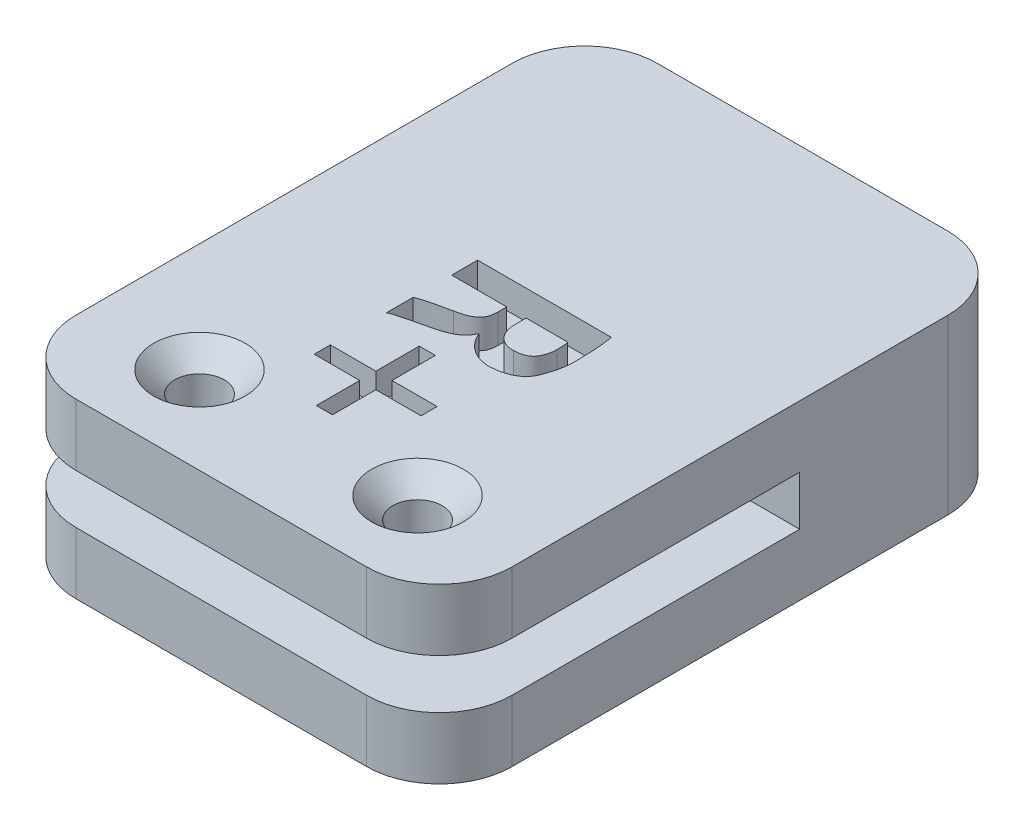
from build123d import *

# Parameters (mm, degrees)
BOSS_EXTRUDE1_DEPTH                                 = 4.25
BOSS_EXTRUDE2_DEPTH                                 = 30
FILLET1_R                                           = 5
CSK_FOR_M3_COUNTERSUNK_FLAT_HEAD_SCREW1_D           = 3.4
CSK_FOR_M3_COUNTERSUNK_FLAT_HEAD_SCREW1_CSINK_D     = 6.3
CSK_FOR_M3_COUNTERSUNK_FLAT_HEAD_SCREW1_CSINK_ANGLE = 90
CUT_EXTRUDE3_DEPTH                                  = 2


with BuildPart() as part:
    # Sketch1 → Boss-Extrude1 (new body)
    with BuildSketch(Plane(origin=(0, 0, 0), x_dir=(1, 0, 0), z_dir=(0, 1, 0))):
        with BuildLine():
            Line((15, 15), (15, 20))
            Line((15, 20), (10, 20))
            Line((10, 20), (-10, 20))
            ThreePointArc((-10, 20), (-13.535533906, 18.535533906), (-15, 15))
            Line((-15, 15), (-15, -15))
            ThreePointArc((-15, -15), (-13.535533906, -18.535533906), (-10, -20))
            Line((-10, -20), (10, -20))
            ThreePointArc((10, -20), (13.535533906, -18.535533906), (15, -15))
            Line((15, -15), (15, 15))
        make_face()
    extrude(amount=BOSS_EXTRUDE1_DEPTH)

    # Sketch8 → Boss-Extrude2 (add)
    with BuildSketch(Plane(origin=(15, 0, 0), x_dir=(0, 0, -1), z_dir=(1, 0, 0))):
        Polygon((4.788040489, 0), (20, 0), (20, -7.65), (5.253900522, -7.65), (-20, -7.65), (-20, -3.4), (4.788040489, -3.4), align=None)
    extrude(amount=-BOSS_EXTRUDE2_DEPTH)

    # Fillet1
    fillet1_edges = [part.edges().sort_by_distance(p)[0] for p in [
        (-15, -5.525, 20),
        (15, -5.525, 20),
        (-15, -3.825, -20),
        (15, -1.7, -20),
    ]]
    fillet(fillet1_edges, radius=FILLET1_R)

    # CSK for M3 Countersunk Flat Head Screw1 (through all)
    with Locations(Plane(origin=(7.5, 4.25, 14), x_dir=(0, 0, 1), z_dir=(0, 1, 0))):
        with Locations((0, 0), (0, -15)):
            CounterSinkHole(CSK_FOR_M3_COUNTERSUNK_FLAT_HEAD_SCREW1_D / 2, CSK_FOR_M3_COUNTERSUNK_FLAT_HEAD_SCREW1_CSINK_D / 2, counter_sink_angle=CSK_FOR_M3_COUNTERSUNK_FLAT_HEAD_SCREW1_CSINK_ANGLE)

    # Sketch16 → Cut-Extrude3 (cut)
    with BuildSketch(Plane(origin=(0, 4.25, 0), x_dir=(1, 0, 0), z_dir=(0, 1, 0))):
        with BuildLine():
            Line((-4.458875061, 2.093953282), (-4.458875061, 0.309949228))
            Line((-4.458875061, 0.309949228), (-0.672122679, 0.309949228))
            Line((-0.672122679, 0.309949228), (-0.672122679, -0.295533742))
            add(Edge.make_bspline(
                [(-0.672122679, -0.295533742), (-0.672504144, -0.346007588), (-0.673250223, -0.444725636), (-0.687535915, -0.588091446), (-0.711269814, -0.723049373), (-0.748906576, -0.848005309), (-0.795186736, -0.964950699), (-0.856795731, -1.071025204), (-0.926036377, -1.170327836), (-1.010647749, -1.259432456), (-1.109289731, -1.34061223), (-1.221698501, -1.418754612), (-1.353111911, -1.488366917), (-1.500999377, -1.552487837), (-1.66430924, -1.614037158), (-1.844048215, -1.67060951), (-2.041510814, -1.718785961), (-2.179182831, -1.747242983), (-2.25068209, -1.762021993)],
                knots=[0, 0, 0, 0, 0.000151354, 0.000296022, 0.000431716, 0.000561725, 0.000686937, 0.000808031, 0.00092887, 0.001049364, 0.001175264, 0.001311639, 0.001459344, 0.001620515, 0.001794996, 0.001982705, 0.00218542, 0.002404451, 0.002404451, 0.002404451, 0.002404451], degree=3))
            add(Edge.make_bspline(
                [(-2.25068209, -1.762021993), (-2.387123246, -1.789200508), (-2.648649934, -1.841295546), (-3.023584407, -1.921428366), (-3.362673147, -2.002832785), (-3.666100231, -2.077858492), (-3.927379781, -2.154644362), (-4.146751884, -2.219240543), (-4.32008565, -2.279378782), (-4.417682148, -2.322811057), (-4.45961412, -2.341471572)],
                knots=[0, 0, 0, 0, 0.000417367, 0.000799998, 0.001150089, 0.001463532, 0.001737527, 0.001966934, 0.002149658, 0.002287303, 0.002287303, 0.002287303, 0.002287303], degree=3))
            Line((-4.45961412, -2.341471572), (-4.458875061, -4.175738487))
            add(Edge.make_bspline(
                [(-4.458875061, -4.175738487), (-4.402589194, -4.151927467), (-4.273325007, -4.097243897), (-4.049026625, -4.021563183), (-3.76980856, -3.944375115), (-3.44421419, -3.85993596), (-3.082911414, -3.77340803), (-2.69996289, -3.679173777), (-2.299298994, -3.5850796), (-2.02650801, -3.520868388), (-1.887209172, -3.488079375)],
                knots=[0, 0, 0, 0, 0.000183303, 0.000420968, 0.000709434, 0.001052273, 0.001430025, 0.001823964, 0.002235386, 0.002664705, 0.002664705, 0.002664705, 0.002664705], degree=3))
            add(Edge.make_bspline(
                [(-1.887209172, -3.488079375), (-1.773168942, -3.460587046), (-1.5527428, -3.40744766), (-1.242137194, -3.301932392), (-0.961961493, -3.180824272), (-0.712628496, -3.043118308), (-0.494327391, -2.883770123), (-0.309294243, -2.700614679), (-0.160659908, -2.489955128), (-0.089741414, -2.335127445), (-0.054041414, -2.257187997)],
                knots=[0, 0, 0, 0, 0.000351778, 0.000679945, 0.00098268, 0.001266475, 0.001532679, 0.001790935, 0.002044255, 0.002301038, 0.002301038, 0.002301038, 0.002301038], degree=3))
            Line((-0.054041414, -2.257187997), (-0.017001018, -2.256815895))
            add(Edge.make_bspline(
                [(-0.017001018, -2.256815895), (0.029911866, -2.365823451), (0.123313913, -2.582853997), (0.323884915, -2.877351795), (0.561124066, -3.147418036), (0.791801521, -3.347016191), (0.996667391, -3.486871195), (1.159796885, -3.579888369), (1.331125187, -3.659692635), (1.511272618, -3.724161338), (1.699423762, -3.777423006), (1.896777905, -3.815590183), (2.10218195, -3.840681678), (2.242029099, -3.845564971), (2.31292232, -3.848040477)],
                knots=[0, 0, 0, 0, 0.000355311, 0.000707414, 0.001063218, 0.001431749, 0.001618768, 0.001806724, 0.001994483, 0.002185005, 0.002380132, 0.002580552, 0.002787459, 0.003000185, 0.003000185, 0.003000185, 0.003000185], degree=3))
            add(Edge.make_bspline(
                [(2.31292232, -3.848040477), (2.385587327, -3.843063086), (2.528387107, -3.833281621), (2.736157027, -3.804081983), (2.934377079, -3.769477794), (3.12157362, -3.72614897), (3.298551, -3.672971002), (3.465300172, -3.611887222), (3.621747563, -3.542152622), (3.767015737, -3.462240208), (3.901655002, -3.374411599), (4.028165561, -3.280431232), (4.139686737, -3.173179002), (4.245201989, -3.061210534), (4.337161514, -2.937791912), (4.421171972, -2.806974416), (4.492481699, -2.666595654), (4.572833747, -2.470528249), (4.655111908, -2.221765184), (4.747022893, -1.928865862), (4.815938639, -1.640339407), (4.873772811, -1.360763019), (4.911134187, -1.087285562), (4.938041391, -0.821456672), (4.942448373, -0.562034079), (4.934759857, -0.391801423), (4.930980872, -0.308130323)],
                knots=[0, 0, 0, 0, 0.000218439, 0.000429273, 0.000629045, 0.000821988, 0.00100531, 0.001183082, 0.001354416, 0.001518656, 0.001679866, 0.001836496, 0.001990536, 0.002143381, 0.002297551, 0.002451481, 0.002609328, 0.002769115, 0.003086745, 0.003395031, 0.003689736, 0.003976245, 0.004251139, 0.004517418, 0.004777346, 0.005028594, 0.005028594, 0.005028594, 0.005028594], degree=3))
            add(Edge.make_bspline(
                [(4.930980872, -0.308130323), (4.928380241, -0.083891229), (4.92331038, 0.353257086), (4.887880892, 0.889981636), (4.849888886, 1.296449232), (4.81849973, 1.578640143), (4.783827219, 1.842751715), (4.756374827, 2.012069012), (4.743098736, 2.093951568)],
                knots=[0, 0, 0, 0, 0.000672659, 0.001311332, 0.001612904, 0.001897366, 0.002163083, 0.002411927, 0.002411927, 0.002411927, 0.002411927], degree=3))
            Line((4.743098736, 2.093951568), (-4.458875061, 2.093953282))
        make_face()
        with BuildLine():
            add(Edge.make_bspline(
                [(3.524901679, 0.309949228), (3.5362357, 0.265056815), (3.562459702, 0.161187345), (3.581770379, -0.022092437), (3.596059535, -0.251690395), (3.596338527, -0.421053384), (3.596490933, -0.513571537)],
                knots=[0, 0, 0, 0, 0.000138759, 0.000321052, 0.000551505, 0.00082896, 0.00082896, 0.00082896, 0.00082896], degree=3))
            add(Edge.make_bspline(
                [(3.596490933, -0.513571537), (3.597082169, -0.601000244), (3.598262348, -0.775518572), (3.546964591, -1.035855351), (3.4603018, -1.291694822), (3.357800432, -1.499038994), (3.250131892, -1.654091538), (3.148195375, -1.757518057), (3.02726046, -1.845102985), (2.888483977, -1.920565561), (2.729515001, -1.975864581), (2.554400178, -2.022986207), (2.359997891, -2.051855745), (2.224042634, -2.059862294), (2.153134709, -2.064038137)],
                knots=[0, 0, 0, 0, 0.000261725, 0.000522434, 0.000791185, 0.001070744, 0.001213016, 0.001355807, 0.001504013, 0.001659567, 0.001827887, 0.002007617, 0.002203059, 0.002416111, 0.002416111, 0.002416111, 0.002416111], degree=3))
            add(Edge.make_bspline(
                [(2.153134709, -2.064038137), (2.098038917, -2.062071411), (1.990380235, -2.058228374), (1.833615321, -2.036444408), (1.684147968, -2.004273349), (1.544949695, -1.954070069), (1.412062778, -1.894607052), (1.289839735, -1.818968912), (1.176559769, -1.72966981), (1.070777099, -1.630128202), (0.976208078, -1.517460335), (0.892824958, -1.394333332), (0.82440131, -1.258660147), (0.766734521, -1.113542778), (0.720573152, -0.95726533), (0.688091814, -0.790869848), (0.666338768, -0.613623823), (0.662560413, -0.491981725), (0.660613067, -0.429287962)],
                knots=[0, 0, 0, 0, 0.000165289, 0.000322979, 0.000474201, 0.000623029, 0.000766025, 0.000910277, 0.001052884, 0.001198201, 0.001345237, 0.001493286, 0.00164328, 0.001800117, 0.00196124, 0.002131355, 0.002308205, 0.002496292, 0.002496292, 0.002496292, 0.002496292], degree=3))
            Line((0.660613067, -0.429287962), (0.66236726, 0.309949228))
            Line((0.66236726, 0.309949228), (3.524901679, 0.309949228))
        make_face(mode=Mode.SUBTRACT)
        Polygon((-0.236655826, -5.03436712), (-1.34639128, -5.03436712), (-1.34639128, -8.020075729), (-4.477744211, -8.020075729), (-4.477744211, -9.129811183), (-1.34639128, -9.129811183), (-1.34639128, -12.115519792), (-0.236655826, -12.115519792), (-0.236655826, -9.129811183), (2.870423051, -9.129811183), (2.870423051, -8.020075729), (-0.236655826, -8.020075729), align=None)
    extrude(amount=-CUT_EXTRUDE3_DEPTH, mode=Mode.SUBTRACT)


solid = part.part
